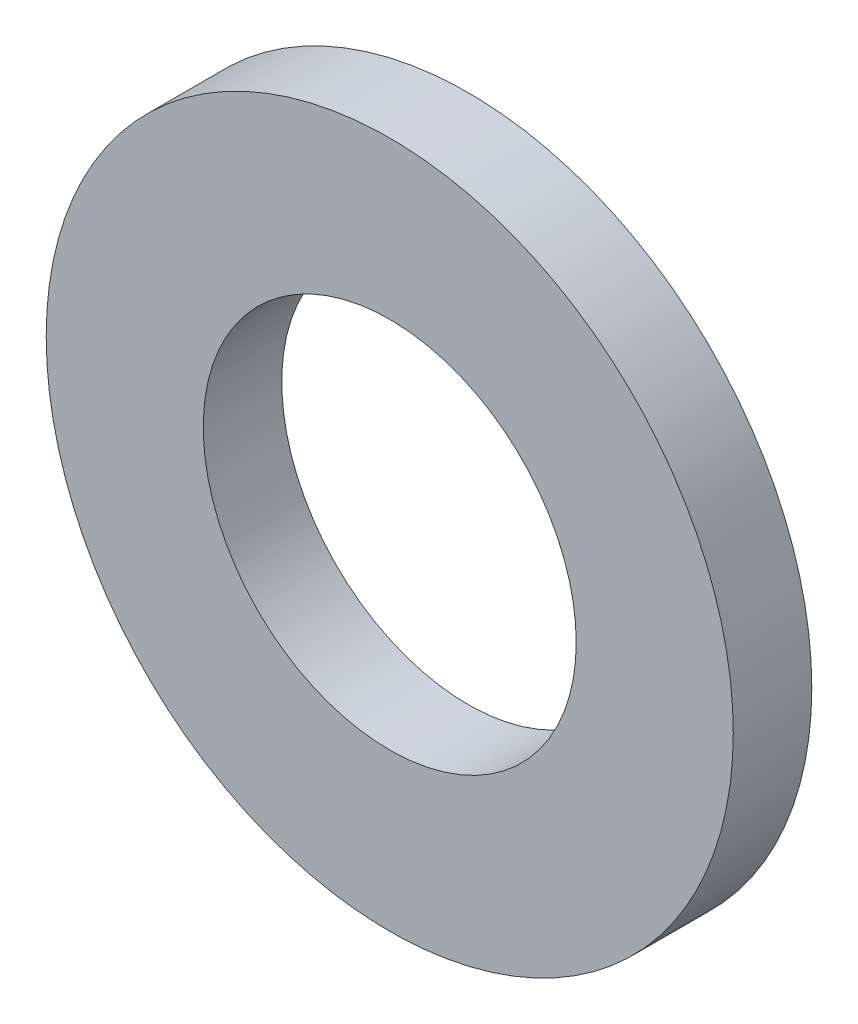
from build123d import *

# Parameters (mm, degrees)
ESQUISSE1_R      = 3.5
ESQUISSE1_R_2    = 1.9
EXTRUSION1_DEPTH = 0.8


with BuildPart() as part:
    # Esquisse1 → Extrusion1 (new body)
    with BuildSketch(Plane.XY):
        Circle(ESQUISSE1_R)
        Circle(ESQUISSE1_R_2, mode=Mode.SUBTRACT)
    extrude(amount=EXTRUSION1_DEPTH)


solid = part.part
